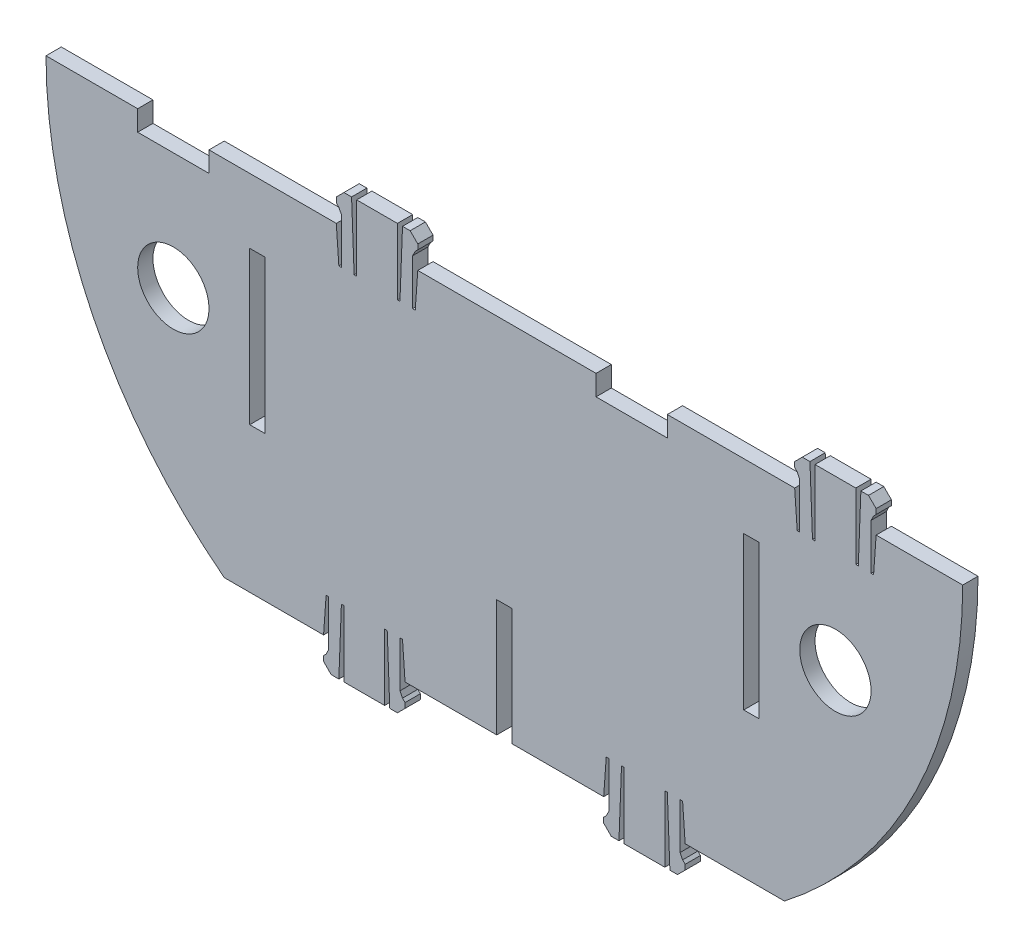
from build123d import *

# Parameters (mm, degrees)
BOSS_EXTRUDE1_DEPTH     = 3
SKETCH5_W               = 3
SKETCH5_H               = 30
CUT_EXTRUDE3_DEPTH      = 3
SKETCH7_R               = 7
CUT_EXTRUDE4_DEPTH      = 3
CUT_EXTRUDE6_DEPTH      = 1
CUT_EXTRUDE6_DEPTH_BACK = 3


with BuildPart() as part:
    # Sketch1 → Boss-Extrude1 (new body)
    with BuildSketch(Plane.XY):
        with BuildLine():
            Line((-55, -71.239034244), (-35.5, -71.239034244))
            Line((-35.5, -71.239034244), (-35, -64.236863152))
            Line((-35, -64.236863152), (-34.5, -64.236863152))
            Line((-34.5, -64.236863152), (-34.5, -73.236863152))
            Line((-34.5, -73.236863152), (-35, -74.236863152))
            Line((-35, -74.236863152), (-35.5, -74.736863152))
            Line((-35.5, -74.736863152), (-35.5, -75.736863152))
            Line((-35.5, -75.736863152), (-34, -77.236863152))
            Line((-34, -77.236863152), (-32.5, -77.236863152))
            Line((-32.5, -77.236863152), (-32, -64.236863152))
            Line((-32, -64.236863152), (-31.5, -64.236863152))
            Line((-31.5, -64.236863152), (-31.5, -77.236863152))
            Line((-31.5, -77.236863152), (-23.5, -77.236863152))
            Line((-23.5, -77.236863152), (-23.5, -64.236863152))
            Line((-23.5, -64.236863152), (-23, -64.236863152))
            Line((-23, -64.236863152), (-22.5, -77.236863152))
            Line((-22.5, -77.236863152), (-21, -77.236863152))
            Line((-21, -77.236863152), (-19.5, -75.736863152))
            Line((-19.5, -75.736863152), (-19.5, -74.736863152))
            Line((-19.5, -74.736863152), (-20, -74.236863152))
            Line((-20, -74.236863152), (-20.5, -73.236863152))
            Line((-20.5, -73.236863152), (-20.5, -64.236863152))
            Line((-20.5, -64.236863152), (-20, -64.236863152))
            Line((-20, -64.236863152), (-19.5, -71.239034244))
            Line((-19.5, -71.239034244), (19.5, -71.239034244))
            Line((19.5, -71.239034244), (20, -64.236863152))
            Line((20, -64.236863152), (20.5, -64.236863152))
            Line((20.5, -64.236863152), (20.5, -73.236863152))
            Line((20.5, -73.236863152), (20, -74.236863152))
            Line((20, -74.236863152), (19.5, -74.736863152))
            Line((19.5, -74.736863152), (19.5, -75.736863152))
            Line((19.5, -75.736863152), (21, -77.236863152))
            Line((21, -77.236863152), (22.5, -77.236863152))
            Line((22.5, -77.236863152), (23, -64.236863152))
            Line((23, -64.236863152), (23.5, -64.236863152))
            Line((23.5, -64.236863152), (23.5, -77.236863152))
            Line((23.5, -77.236863152), (31.5, -77.236863152))
            Line((31.5, -77.236863152), (31.5, -64.236863152))
            Line((31.5, -64.236863152), (32, -64.236863152))
            Line((32, -64.236863152), (32.5, -77.236863152))
            Line((32.5, -77.236863152), (34, -77.236863152))
            Line((34, -77.236863152), (35.5, -75.736863152))
            Line((35.5, -75.736863152), (35.5, -74.736863152))
            Line((35.5, -74.736863152), (35, -74.236863152))
            Line((35, -74.236863152), (34.5, -73.236863152))
            Line((34.5, -73.236863152), (34.5, -64.236863152))
            Line((34.5, -64.236863152), (35, -64.236863152))
            Line((35, -64.236863152), (35.5, -71.239034244))
            Line((35.5, -71.239034244), (55, -71.239034244))
            ThreePointArc((55, -71.239034244), (80.777472107, -39.686269666), (90, 0))
            Line((90, 0), (73, 0))
            Line((73, 0), (72.5, -7.002171092))
            Line((72.5, -7.002171092), (72, -7.002171092))
            Line((72, -7.002171092), (72, 1.997828908))
            Line((72, 1.997828908), (72.5, 2.997828908))
            Line((72.5, 2.997828908), (73, 3.497828908))
            Line((73, 3.497828908), (73, 4.497828908))
            Line((73, 4.497828908), (71.5, 5.997828908))
            Line((71.5, 5.997828908), (70, 5.997828908))
            Line((70, 5.997828908), (69.5, -7.002171092))
            Line((69.5, -7.002171092), (69, -7.002171092))
            Line((69, -7.002171092), (69, 5.997828908))
            Line((69, 5.997828908), (61, 5.997828908))
            Line((61, 5.997828908), (61, -7.002171092))
            Line((61, -7.002171092), (60.5, -7.002171092))
            Line((60.5, -7.002171092), (60, 5.997828908))
            Line((60, 5.997828908), (58.5, 5.997828908))
            Line((58.5, 5.997828908), (57, 4.497828908))
            Line((57, 4.497828908), (57, 3.497828908))
            Line((57, 3.497828908), (57.5, 2.997828908))
            Line((57.5, 2.997828908), (58, 1.997828908))
            Line((58, 1.997828908), (58, -7.002171092))
            Line((58, -7.002171092), (57.5, -7.002171092))
            Line((57.5, -7.002171092), (57, 0))
            Line((57, 0), (32, 0))
            Line((32, 0), (32, -4))
            Line((32, -4), (18, -4))
            Line((18, -4), (18, 0))
            Line((18, 0), (-17, 0))
            Line((-17, 0), (-17.5, -7.002171092))
            Line((-17.5, -7.002171092), (-18, -7.002171092))
            Line((-18, -7.002171092), (-18, 1.997828908))
            Line((-18, 1.997828908), (-17.5, 2.997828908))
            Line((-17.5, 2.997828908), (-17, 3.497828908))
            Line((-17, 3.497828908), (-17, 4.497828908))
            Line((-17, 4.497828908), (-18.5, 5.997828908))
            Line((-18.5, 5.997828908), (-20, 5.997828908))
            Line((-20, 5.997828908), (-20.5, -7.002171092))
            Line((-20.5, -7.002171092), (-21, -7.002171092))
            Line((-21, -7.002171092), (-21, 5.997828908))
            Line((-21, 5.997828908), (-29, 5.997828908))
            Line((-29, 5.997828908), (-29, -7.002171092))
            Line((-29, -7.002171092), (-29.5, -7.002171092))
            Line((-29.5, -7.002171092), (-30, 5.997828908))
            Line((-30, 5.997828908), (-31.5, 5.997828908))
            Line((-31.5, 5.997828908), (-33, 4.497828908))
            Line((-33, 4.497828908), (-33, 3.497828908))
            Line((-33, 3.497828908), (-32.5, 2.997828908))
            Line((-32.5, 2.997828908), (-32, 1.997828908))
            Line((-32, 1.997828908), (-32, -7.002171092))
            Line((-32, -7.002171092), (-32.5, -7.002171092))
            Line((-32.5, -7.002171092), (-33, 0))
            Line((-33, 0), (-58, 0))
            Line((-58, 0), (-58, -4))
            Line((-58, -4), (-72, -4))
            Line((-72, -4), (-72, 0))
            Line((-72, 0), (-90, 0))
            ThreePointArc((-90, 0), (-80.777472107, -39.686269666), (-55, -71.239034244))
        make_face()
    extrude(amount=BOSS_EXTRUDE1_DEPTH)

    # Sketch5 → Cut-Extrude3 (cut)
    with BuildSketch(Plane(origin=(0, 0, 0), x_dir=(-1, 0, 0), z_dir=(0, 0, -1))):
        with Locations((-48.5, -27.74)):
            Rectangle(SKETCH5_W, SKETCH5_H)
        with Locations((48.5, -27.74)):
            Rectangle(SKETCH5_W, SKETCH5_H)
    extrude(amount=-CUT_EXTRUDE3_DEPTH, mode=Mode.SUBTRACT)

    # Sketch7 → Cut-Extrude4 (cut)
    with BuildSketch(Plane(origin=(0, 0, 0), x_dir=(-1, 0, 0), z_dir=(0, 0, -1))):
        with Locations((65, -27)):
            Circle(SKETCH7_R)
        with Locations((-65, -27)):
            Circle(SKETCH7_R)
    extrude(amount=-CUT_EXTRUDE4_DEPTH, mode=Mode.SUBTRACT)

    # Sketch8 → Cut-Extrude6 (cut, two sides)
    with BuildSketch(Plane(origin=(0, 0, 0), x_dir=(-1, 0, 0), z_dir=(0, 0, -1))) as cut_extrude6_sk:
        Polygon((-1.5, -320.719998244), (-1.5, -71.239034244), (-1.5, -48.239034244), (1.5, -48.239034244), (1.5, -71.239034244), (1.5, -320.719998244), (1.5, -819.681926243), (-1.5, -819.681926243), align=None)
    extrude(amount=CUT_EXTRUDE6_DEPTH, mode=Mode.SUBTRACT)
    extrude(cut_extrude6_sk.sketch, amount=-CUT_EXTRUDE6_DEPTH_BACK, mode=Mode.SUBTRACT)


solid = part.part
